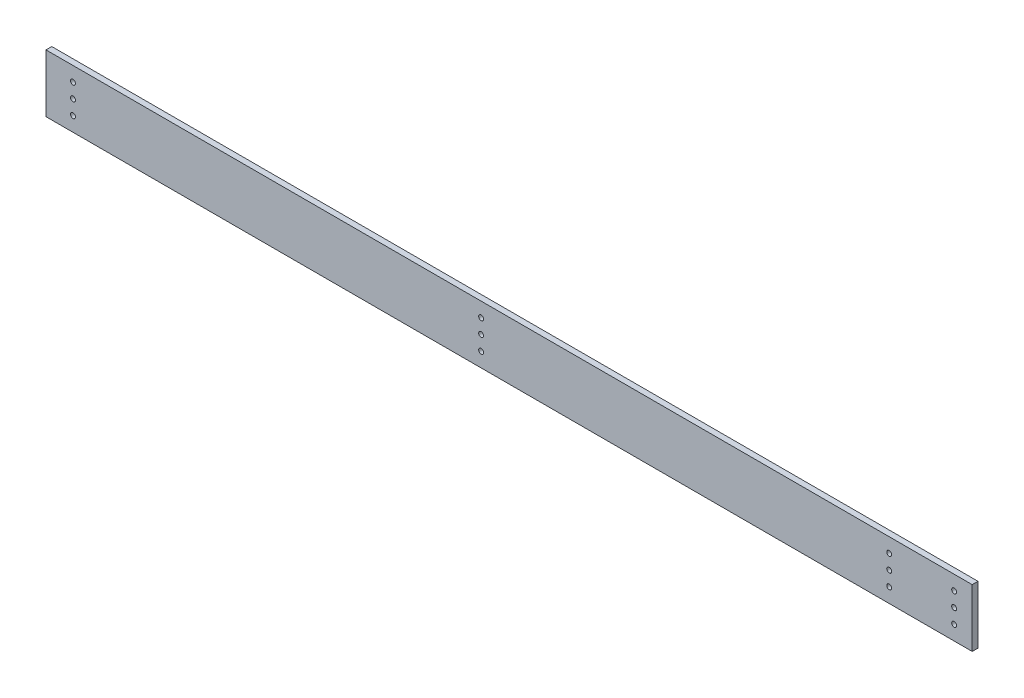
from build123d import *

# Parameters (mm, degrees)
SKETCH1_W           = 508
SKETCH1_H           = 31.75
BOSS_EXTRUDE1_DEPTH = 3.175
SKETCH2_R           = 1.3589
CUT_EXTRUDE1_DEPTH  = 4.175


with BuildPart() as part:
    # Sketch1 → Boss-Extrude1 (new body)
    with BuildSketch(Plane.XY):
        with Locations((254, 15.875)):
            Rectangle(SKETCH1_W, SKETCH1_H)
    extrude(amount=BOSS_EXTRUDE1_DEPTH)

    # Sketch2 → Cut-Extrude1 (cut, through all)
    with BuildSketch(Plane.XY.offset(3.175)):
        with Locations((14.8082, 23.8252)):
            Circle(SKETCH2_R)
        with Locations((14.8082, 15.875)):
            Circle(SKETCH2_R)
        with Locations((14.8082, 7.9248)):
            Circle(SKETCH2_R)
        with Locations((462.4832, 23.8252)):
            Circle(SKETCH2_R)
        with Locations((462.4832, 15.875)):
            Circle(SKETCH2_R)
        with Locations((462.4832, 7.9248)):
            Circle(SKETCH2_R)
        with Locations((498.094, 23.8252)):
            Circle(SKETCH2_R)
        with Locations((498.094, 15.875)):
            Circle(SKETCH2_R)
        with Locations((498.094, 7.9248)):
            Circle(SKETCH2_R)
        with Locations((238.6584, 23.8252)):
            Circle(SKETCH2_R)
        with Locations((238.6584, 15.875)):
            Circle(SKETCH2_R)
        with Locations((238.6584, 7.9248)):
            Circle(SKETCH2_R)
    extrude(amount=-CUT_EXTRUDE1_DEPTH, mode=Mode.SUBTRACT)


solid = part.part
